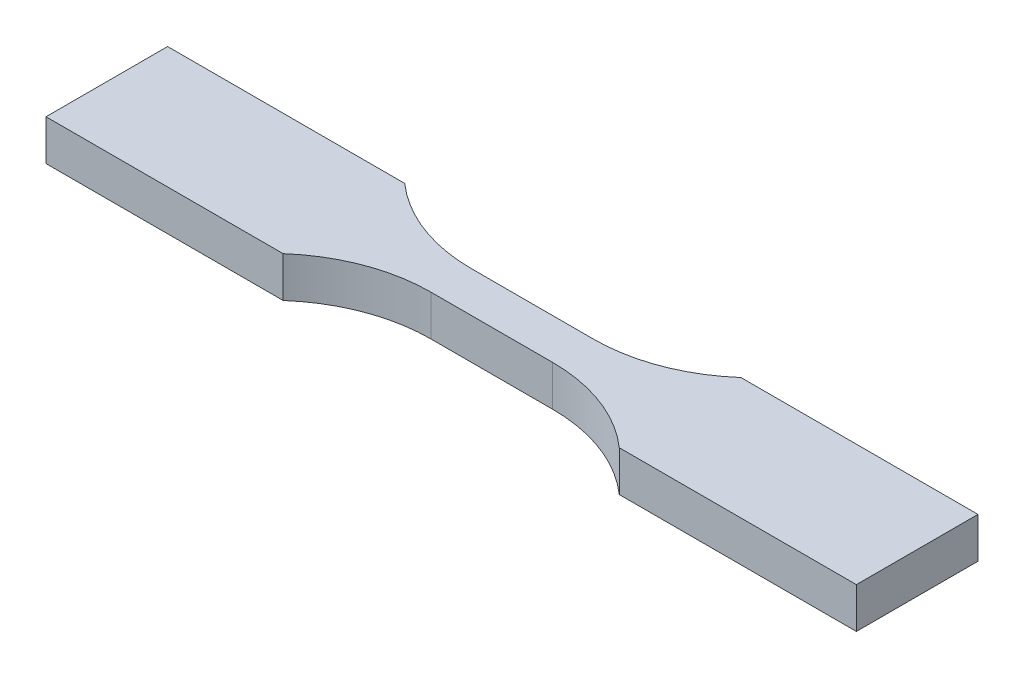
from build123d import *

# Parameters (mm, degrees)
SALIENTE_EXTRUIR1_DEPTH = 3.18


with BuildPart() as part:
    # Croquis1 → Saliente-Extruir1 (new body)
    with BuildSketch(Plane(origin=(0, 0, 0), x_dir=(1, 0, 0), z_dir=(0, 1, 0))):
        with BuildLine():
            Line((-4.765, 1.59418202), (4.765, 1.59418202))
            ThreePointArc((4.765, 1.59418202), (9.257217817, 2.411625687), (13.17, 4.765))
            Line((13.17, 4.765), (31.75, 4.765))
            Line((31.75, 4.765), (31.75, -4.765))
            Line((31.75, -4.765), (13.17, -4.765))
            ThreePointArc((13.17, -4.765), (9.258084222, -2.407173521), (4.765, -1.58581798))
            Line((4.765, -1.58581798), (-4.765, -1.58581798))
            ThreePointArc((-4.765, -1.58581798), (-9.258084222, -2.407173521), (-13.17, -4.765))
            Line((-13.17, -4.765), (-31.75, -4.765))
            Line((-31.75, -4.765), (-31.75, 4.765))
            Line((-31.75, 4.765), (-13.17, 4.765))
            ThreePointArc((-13.17, 4.765), (-9.257217817, 2.411625687), (-4.765, 1.59418202))
        make_face()
    extrude(amount=SALIENTE_EXTRUIR1_DEPTH)


solid = part.part
